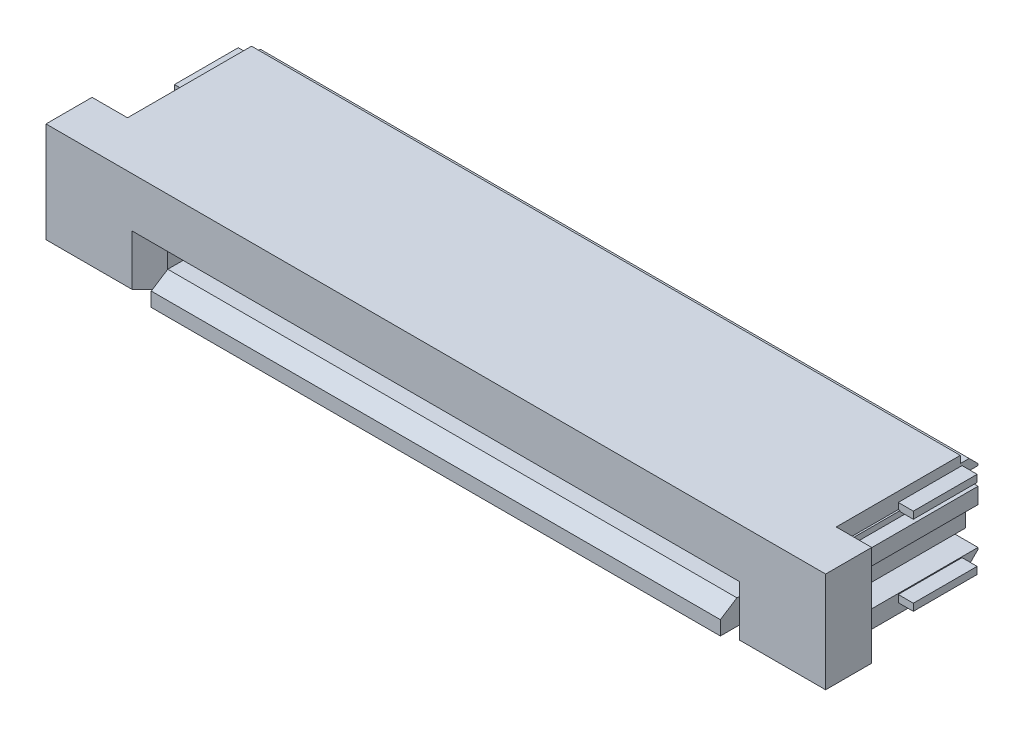
from build123d import *

# Parameters (mm, degrees)
BASE_DEPTH              = 10
SKETCH2_W               = 16.2
SKETCH2_H               = 1.55
CARD_SLOT_DEPTH         = 3.8
SKETCH4_W               = 1.775
SKETCH4_H               = 2
WINGS_DEPTH             = 5
SKETCH5_W               = 1.97
SKETCH5_H               = 3
FRONT_LEAD_IN_DEPTH     = 1.3
CARD_SLOT_LEAD_IN_SIZE  = 0.1
CARD_SLOT_LEAD_IN_SIZE2 = 0.173205081
WT_DEPTH                = 1.8
GATE_DEPTH              = 1.3
GATE_CHAMFER_SIZE       = 0.5
GATE_GUIDE_DEPTH        = 3.6
F_01_CONTACT_DEPTH      = 0.125
LPATTERN3_COUNT         = 15
LPATTERN3_PITCH         = 1


with BuildPart() as part:
    # Sketch1 → Base (new body, symmetric)
    with BuildSketch(Plane(origin=(0, 0, 0), x_dir=(0, 0, -1), z_dir=(1, 0, 0))):
        Polygon((-1.75, 1.5), (1.75, 1.5), (1.75, 1.3), (2, 1.3), (2.25, 1.05), (2.25, -1.05), (2, -1.3), (1.75, -1.3), (1.75, -1.5), (-3.05, -1.5), (-3.05, -1.1), (-2.35, -0.65), (-1.75, -0.65), align=None)
    extrude(amount=BASE_DEPTH, both=True)

    # Sketch2 → Card Slot (cut)
    with BuildSketch(Plane.XY.offset(3.05)):
        with Locations((0, -0.025)):
            Rectangle(SKETCH2_W, SKETCH2_H)
    extrude(amount=-CARD_SLOT_DEPTH, mode=Mode.SUBTRACT)

    # Sketch4 → Wings (cut, through all)
    with BuildSketch(Plane.XY.offset(1.75)):
        with Locations((-9.1125, 0)):
            Rectangle(SKETCH4_W, SKETCH4_H)
        with Locations((9.1125, 0)):
            Rectangle(SKETCH4_W, SKETCH4_H)
    extrude(amount=-WINGS_DEPTH, mode=Mode.SUBTRACT)

    # Sketch5 → Front Lead In (cut)
    with BuildSketch(Plane.XY.offset(3.05)):
        with Locations((-9.015, 0)):
            Rectangle(SKETCH5_W, SKETCH5_H)
        with Locations((9.015, 0)):
            Rectangle(SKETCH5_W, SKETCH5_H)
    extrude(amount=-FRONT_LEAD_IN_DEPTH, mode=Mode.SUBTRACT)

    # Card Slot Lead In
    card_slot_lead_in_edges = [part.edges().sort_by_distance(p)[0] for p in [
        (0, 0.75, 1.75),
        (-8.1, -0.025, 1.75),
        (8.1, -0.025, 1.75),
    ]]
    card_slot_lead_in_side = [part.faces().sort_by_distance(p)[0] for p in [
        (0, 0.819195673, 1.75),
    ]]
    chamfer(card_slot_lead_in_edges, length=CARD_SLOT_LEAD_IN_SIZE, length2=CARD_SLOT_LEAD_IN_SIZE2, reference=card_slot_lead_in_side[0])

    # Sketch8 → WT (add)
    with BuildSketch(Plane.XY):
        with BuildLine():
            Line((-10.425, 1.025), (-8.575, 1.025))
            ThreePointArc((-8.575, 1.025), (-8.468933983, 0.981066017), (-8.425, 0.875))
            Line((-8.425, 0.875), (-8.425, -0.875))
            ThreePointArc((-8.425, -0.875), (-8.468933983, -0.981066017), (-8.575, -1.025))
            Line((-8.575, -1.025), (-10.425, -1.025))
            Line((-10.425, -1.025), (-10.425, -1.225))
            Line((-10.425, -1.225), (-8.575, -1.225))
            ThreePointArc((-8.575, -1.225), (-8.327512627, -1.122487373), (-8.225, -0.875))
            Line((-8.225, -0.875), (-8.225, 0.875))
            ThreePointArc((-8.225, 0.875), (-8.327512627, 1.122487373), (-8.575, 1.225))
            Line((-8.575, 1.225), (-10.425, 1.225))
            Line((-10.425, 1.225), (-10.425, 1.025))
        make_face()
        with BuildLine():
            Line((10.425, 1.025), (8.575, 1.025))
            ThreePointArc((8.575, 1.025), (8.468933983, 0.981066017), (8.425, 0.875))
            Line((8.425, 0.875), (8.425, -0.875))
            ThreePointArc((8.425, -0.875), (8.468933983, -0.981066017), (8.575, -1.025))
            Line((8.575, -1.025), (10.425, -1.025))
            Line((10.425, -1.025), (10.425, -1.225))
            Line((10.425, -1.225), (8.575, -1.225))
            ThreePointArc((8.575, -1.225), (8.327512627, -1.122487373), (8.225, -0.875))
            Line((8.225, -0.875), (8.225, 0.875))
            ThreePointArc((8.225, 0.875), (8.327512627, 1.122487373), (8.575, 1.225))
            Line((8.575, 1.225), (10.425, 1.225))
            Line((10.425, 1.225), (10.425, 1.025))
        make_face()
    extrude(amount=-WT_DEPTH)

    # Sketch9 → Gate (add)
    with BuildSketch(Plane.XY.offset(1.75)):
        Polygon((8.07, 0.1), (8.07, -1.33), (11, -1.33), (11, 1.5), (-11, 1.5), (-11, -1.33), (-8.07, -1.33), (-8.07, 0.1), align=None)
    extrude(amount=GATE_DEPTH)

    # Gate Chamfer
    gate_chamfer_edges = [part.edges().sort_by_distance(p)[0] for p in [
        (-8.07, -0.615, 3.05),
        (8.07, -0.615, 3.05),
    ]]
    chamfer(gate_chamfer_edges, length=GATE_CHAMFER_SIZE)

    # Sketch10 → Gate Guide (add)
    with BuildSketch(Plane(origin=(0, 0, 1.75), x_dir=(-1, 0, 0), z_dir=(0, 0, -1))):
        Polygon((-10.05, -0.3), (-10.05, 0.44506), (-10.4, 0.44506), (-10.4, 0.89506), (-10.05, 0.89506), (-10.05, 1.05), (-9.4, 1.05), (-9.4, 0.375499815), (-9.125, 0.375499815), (-9.125, -0.201850454), (-9.5, -0.201850454), (-9.5, -0.3), align=None)
        Polygon((9.125, -0.201850454), (9.125, 0.375499815), (9.4, 0.375499815), (9.4, 1.05), (10.05, 1.05), (10.05, 0.89506), (10.4, 0.89506), (10.4, 0.44506), (10.05, 0.44506), (10.05, -0.3), (9.5, -0.3), (9.5, -0.201850454), align=None)
    extrude(amount=GATE_GUIDE_DEPTH)

    # Sketch13 → -01 Contact (add, symmetric)
    with BuildSketch(Plane(origin=(7, 0, 0), x_dir=(0, 0, -1), z_dir=(1, 0, 0))):
        with BuildLine():
            ThreePointArc((1.091468707, -0.7696), (1.268245402, -0.696376695), (1.341468707, -0.5196))
            Line((1.341468707, -0.5196), (1.341468707, -0.44900832))
            ThreePointArc((1.341468707, -0.44900832), (1.111505179, 0.091419351), (0.562636527, 0.300437279))
            Line((0.562636527, 0.300437279), (-1.104507646, 0.2363))
            ThreePointArc((-1.104507646, 0.2363), (-1.202075654, 0.195944223), (-1.25, 0.101862545))
            ThreePointArc((-1.25, 0.101862545), (-1.295444824, 0.048293017), (-1.362451828, 0.069387751))
            Line((-1.362451828, 0.069387751), (-1.649820024, 0.424987751))
            ThreePointArc((-1.649820024, 0.424987751), (-1.649328111, 0.505413401), (-1.570395768, 0.520847536))
            ThreePointArc((-1.570395768, 0.520847536), (-1.36954416, 0.449036779), (-1.1564545, 0.4395))
            Line((-1.1564545, 0.4395), (1.138268707, 0.6804))
            Line((1.138268707, 0.6804), (1.551768707, 0.6804))
            ThreePointArc((1.551768707, 0.6804), (1.650551525, 0.639482817), (1.691468707, 0.5407))
            ThreePointArc((1.691468707, 0.5407), (1.830262642, 0.551847257), (1.896637232, 0.67425))
            Line((1.896637232, 0.67425), (1.896637232, 0.677234263))
            ThreePointArc((1.896637232, 0.677234263), (2.07345297, 0.85405), (2.250268707, 0.677234263))
            Line((2.250268707, 0.677234263), (2.250268707, 0.324203125))
            ThreePointArc((2.250268707, 0.324203125), (2.212168707, 0.2234), (2.250268707, 0.122596875))
            Line((2.250268707, 0.122596875), (2.250268707, -0.561796875))
            ThreePointArc((2.250268707, -0.561796875), (2.225665582, -0.725303125), (2.364568707, -0.815))
            Line((2.364568707, -0.815), (2.505907985, -0.815))
            ThreePointArc((2.505907985, -0.815), (2.630745337, -0.837012193), (2.740525462, -0.900393778))
            Line((2.740525462, -0.900393778), (3.069017668, -1.176031466))
            ThreePointArc((3.069017668, -1.176031466), (3.12631387, -1.209111444), (3.191468707, -1.2206))
            Line((3.191468707, -1.2206), (3.648668707, -1.2206))
            ThreePointArc((3.648668707, -1.2206), (3.720510756, -1.250357951), (3.750268707, -1.3222))
            Line((3.750268707, -1.3222), (3.750268707, -1.3984))
            ThreePointArc((3.750268707, -1.3984), (3.720510756, -1.470242049), (3.648668707, -1.5))
            Line((3.648668707, -1.5), (3.191468707, -1.5))
            ThreePointArc((3.191468707, -1.5), (3.030753442, -1.471661563), (2.889422809, -1.390064284))
            Line((2.889422809, -1.390064284), (2.60967503, -1.155328025))
            ThreePointArc((2.60967503, -1.155328025), (2.402653987, -1.096846191), (2.221577699, -1.21298927))
            ThreePointArc((2.221577699, -1.21298927), (2.023089184, -1.285925543), (1.896637232, -1.116434263))
            Line((1.896637232, -1.116434263), (1.896637232, -1.11345))
            ThreePointArc((1.896637232, -1.11345), (1.830262642, -0.991047257), (1.691468707, -0.9799))
            ThreePointArc((1.691468707, -0.9799), (1.650551525, -1.078682817), (1.551768707, -1.1196))
            Line((1.551768707, -1.1196), (-1.375731293, -1.1196))
            ThreePointArc((-1.375731293, -1.1196), (-1.44817573, -1.064011428), (-1.413231293, -0.979648095))
            Line((-1.413231293, -0.979648095), (-1.066821131, -0.779648095))
            ThreePointArc((-1.066821131, -0.779648095), (-1.04873256, -0.772155563), (-1.029321131, -0.7696))
            Line((-1.029321131, -0.7696), (1.091468707, -0.7696))
        make_face()
    f_01_contact = extrude(amount=F_01_CONTACT_DEPTH, both=True)

    # LPattern3: -01 Contact ×15
    with Locations(*[(-i * LPATTERN3_PITCH, 0, 0) for i in range(1, LPATTERN3_COUNT)]):
        add(f_01_contact)


solid = part.part
